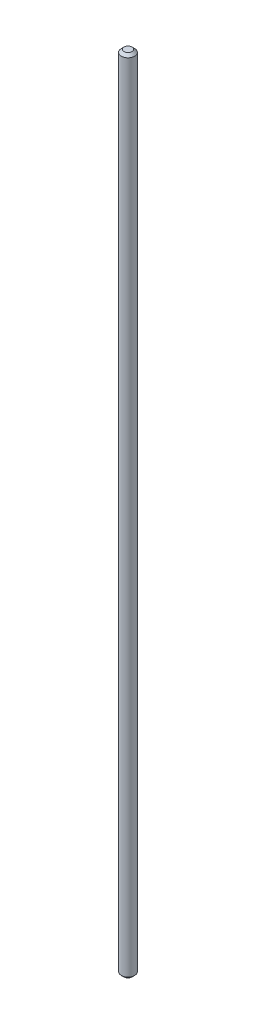
from build123d import *

# Parameters (mm, degrees)
ESQUISSE1_R        = 2.5
BOSS_EXTRU_1_DEPTH = 300
CHANFREIN1_SIZE    = 1


with BuildPart() as part:
    # Esquisse1 → Boss.-Extru.1 (new body)
    with BuildSketch(Plane(origin=(0, 0, 0), x_dir=(1, 0, 0), z_dir=(0, 1, 0))):
        Circle(ESQUISSE1_R)
    extrude(amount=BOSS_EXTRU_1_DEPTH)

    # Chanfrein1
    chanfrein1_edges = [part.edges().sort_by_distance(p)[0] for p in [
        (-2.5, 0, 0),
        (-2.5, 300, 0),
    ]]
    chamfer(chanfrein1_edges, length=CHANFREIN1_SIZE)


solid = part.part
